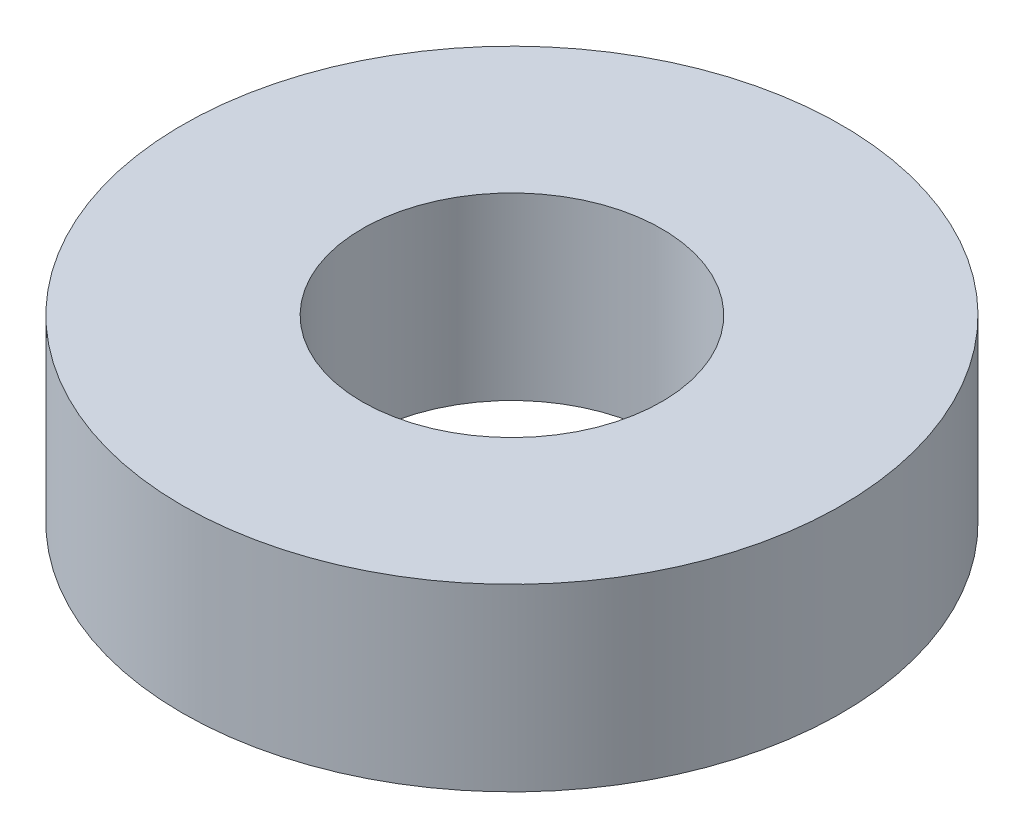
from build123d import *

# Parameters (mm, degrees)
SKETCH_1_R      = 11
SKETCH_1_R_2    = 5
EXTRUDE_1_DEPTH = 6


with BuildPart() as part:
    # 草图1 → 凸台-拉伸1 (new body)
    with BuildSketch(Plane(origin=(0, 0, 0), x_dir=(1, 0, 0), z_dir=(0, 1, 0))):
        Circle(SKETCH_1_R)
        Circle(SKETCH_1_R_2, mode=Mode.SUBTRACT)
    extrude(amount=EXTRUDE_1_DEPTH)


solid = part.part
